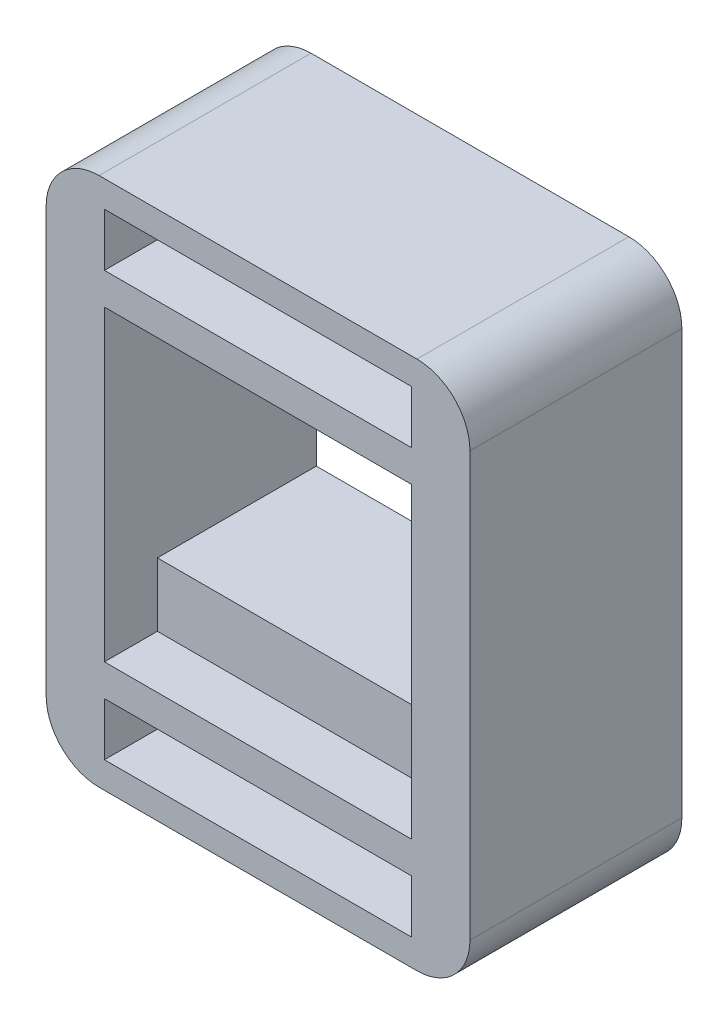
from build123d import *

# Parameters (mm, degrees)
SKETCH2_W           = 29
SKETCH2_H           = 5
BOSS_EXTRUDE2_DEPTH = 20
SKETCH3_W           = 8
SKETCH3_H           = 5
SKETCH3_W_2         = 29
SKETCH3_H_2         = 6
CUT_EXTRUDE1_DEPTH  = 5


with BuildPart() as part:
    # Sketch2 → Boss-Extrude2 (new body)
    with BuildSketch(Plane.XY):
        with BuildLine():
            ThreePointArc((-5.5, -5.5), (-4.035533906, -9.035533906), (-0.5, -10.5))
            Line((-0.5, -10.5), (29.5, -10.5))
            ThreePointArc((29.5, -10.5), (33.035533906, -9.035533906), (34.5, -5.5))
            Line((34.5, -5.5), (34.5, 34.5))
            ThreePointArc((34.5, 34.5), (33.035533906, 38.035533906), (29.5, 39.5))
            Line((29.5, 39.5), (-0.5, 39.5))
            ThreePointArc((-0.5, 39.5), (-4.035533906, 38.035533906), (-5.5, 34.5))
            Line((-5.5, 34.5), (-5.5, -5.5))
        make_face()
        Polygon((29, 6), (0, 6), (0, 24), (8, 24), (8, 29), (21, 29), (21, 24), (29, 24), align=None, mode=Mode.SUBTRACT)
        with Locations((14.5, -5.5)):
            Rectangle(SKETCH2_W, SKETCH2_H, mode=Mode.SUBTRACT)
        with Locations((14.5, 34.5)):
            Rectangle(SKETCH2_W, SKETCH2_H, mode=Mode.SUBTRACT)
    extrude(amount=BOSS_EXTRUDE2_DEPTH)

    # Sketch3 → Cut-Extrude1 (cut)
    with BuildSketch(Plane.XY.offset(20)):
        with Locations((4, 26.5)):
            Rectangle(SKETCH3_W, SKETCH3_H)
        with Locations((25, 26.5)):
            Rectangle(SKETCH3_W, SKETCH3_H)
        with Locations((14.5, 3)):
            Rectangle(SKETCH3_W_2, SKETCH3_H_2)
    extrude(amount=-CUT_EXTRUDE1_DEPTH, mode=Mode.SUBTRACT)


solid = part.part
